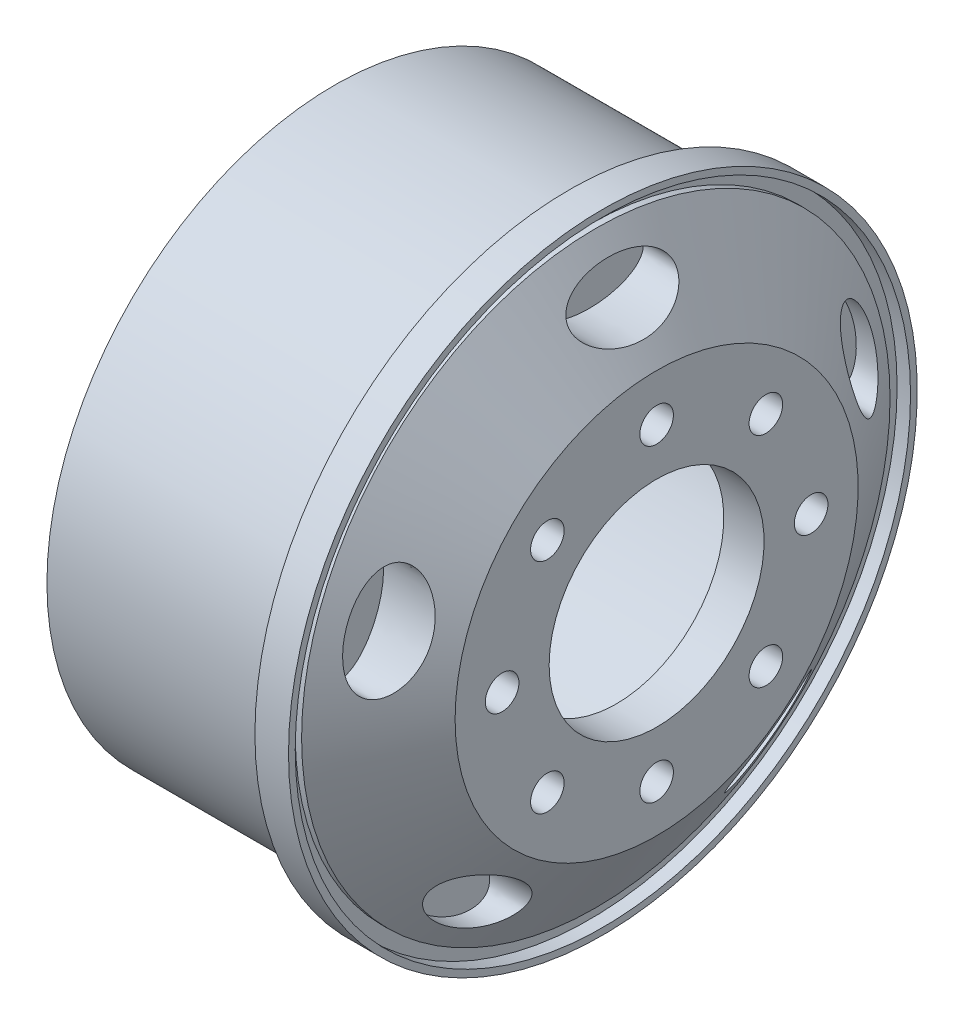
from build123d import *

# Parameters (mm, degrees)
SKETCH4_R          = 1.25
SKETCH4_RX         = 4
SKETCH4_RY         = 2
CUT_EXTRUDE1_DEPTH = 5


with BuildPart() as part:
    # Sketch3 → Revolve1 (revolve)
    with BuildSketch(Plane(origin=(0, 0, 0), x_dir=(1, 0, 0), z_dir=(0, 1, 0))):
        Polygon((10.36932978, 23.4), (8.86932978, 23.4), (8.86932978, 21.4), (-8.61067022, 21.4), (-8.61067022, 18.231946605), (9.211549898, 18.231946605), (12.36932978, 13.417613419), (12.36932978, 8), (15.36932978, 8), (15.36932978, 15), (10.843535586, 21.9), (10.36932978, 21.9), (10.36932978, 22.9), (11.36932978, 22.9), (11.36932978, 23.4), align=None)
    revolve(axis=Axis((-29.774212385, 0, 0), (1, 0, 0)))

    # Sketch4 → Cut-Extrude1 (cut)
    with BuildSketch(Plane(origin=(15.36932978, 0, 0), x_dir=(0, 0, -1), z_dir=(1, 0, 0))):
        with Locations((0, 11.5)):
            Circle(SKETCH4_R)
        with Locations((8.131727984, 8.131727984)):
            Circle(SKETCH4_R)
        with Locations((11.5, 0)):
            Circle(SKETCH4_R)
        with Locations((8.131727984, -8.131727984)):
            Circle(SKETCH4_R)
        with Locations((0, -11.5)):
            Circle(SKETCH4_R)
        with Locations((-8.131727984, -8.131727984)):
            Circle(SKETCH4_R)
        with Locations((-11.5, 0)):
            Circle(SKETCH4_R)
        with Locations((-8.131727984, 8.131727984)):
            Circle(SKETCH4_R)
        with Locations((0, 18.5)):
            Ellipse(SKETCH4_RX, SKETCH4_RY)
        with Locations(Location((17.594545551, 5.716814396), (0, 0, -72))):
            Ellipse(SKETCH4_RX, SKETCH4_RY)
        with Locations(Location((10.874027167, -14.966814396), (0, 0, -144))):
            Ellipse(SKETCH4_RX, SKETCH4_RY)
        with Locations(Location((-10.874027167, -14.966814396), (0, 0, 144))):
            Ellipse(SKETCH4_RX, SKETCH4_RY)
        with Locations(Location((-17.594545551, 5.716814396), (0, 0, 72))):
            Ellipse(SKETCH4_RX, SKETCH4_RY)
    extrude(amount=-CUT_EXTRUDE1_DEPTH, mode=Mode.SUBTRACT)


solid = part.part
